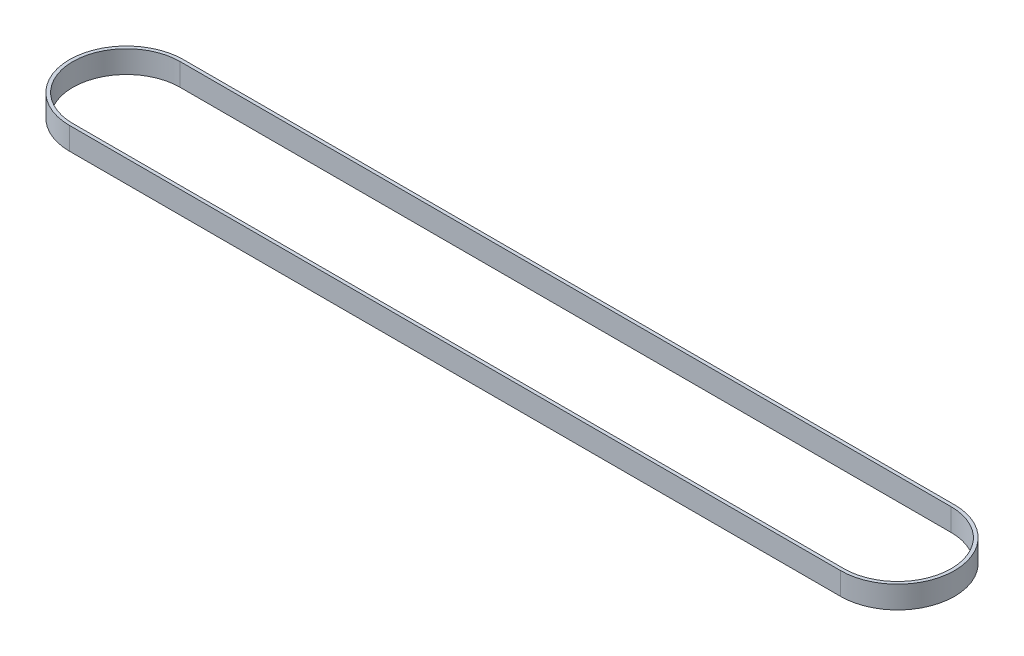
from build123d import *

# Parameters (mm, degrees)
BOSS_EXTRUDE1_DEPTH = 10


with BuildPart() as part:
    # Sketch1 → Boss-Extrude1 (new body)
    with BuildSketch(Plane(origin=(0, 0, 0), x_dir=(1, 0, 0), z_dir=(0, 1, 0))):
        with BuildLine():
            Line((-115.321505596, 25.5), (229.678494404, 25.5))
            ThreePointArc((229.678494404, 25.5), (255.178494404, 0), (229.678494404, -25.5))
            Line((229.678494404, -25.5), (-115.321505596, -25.5))
            ThreePointArc((-115.321505596, -25.5), (-140.821505596, 0), (-115.321505596, 25.5))
        make_face()
        with BuildLine():
            Line((-115.321505596, -24), (229.678494404, -24))
            ThreePointArc((229.678494404, -24), (253.678494404, 0), (229.678494404, 24))
            Line((229.678494404, 24), (-115.321505596, 24))
            ThreePointArc((-115.321505596, 24), (-139.321505596, 0), (-115.321505596, -24))
        make_face(mode=Mode.SUBTRACT)
    extrude(amount=BOSS_EXTRUDE1_DEPTH)


solid = part.part
